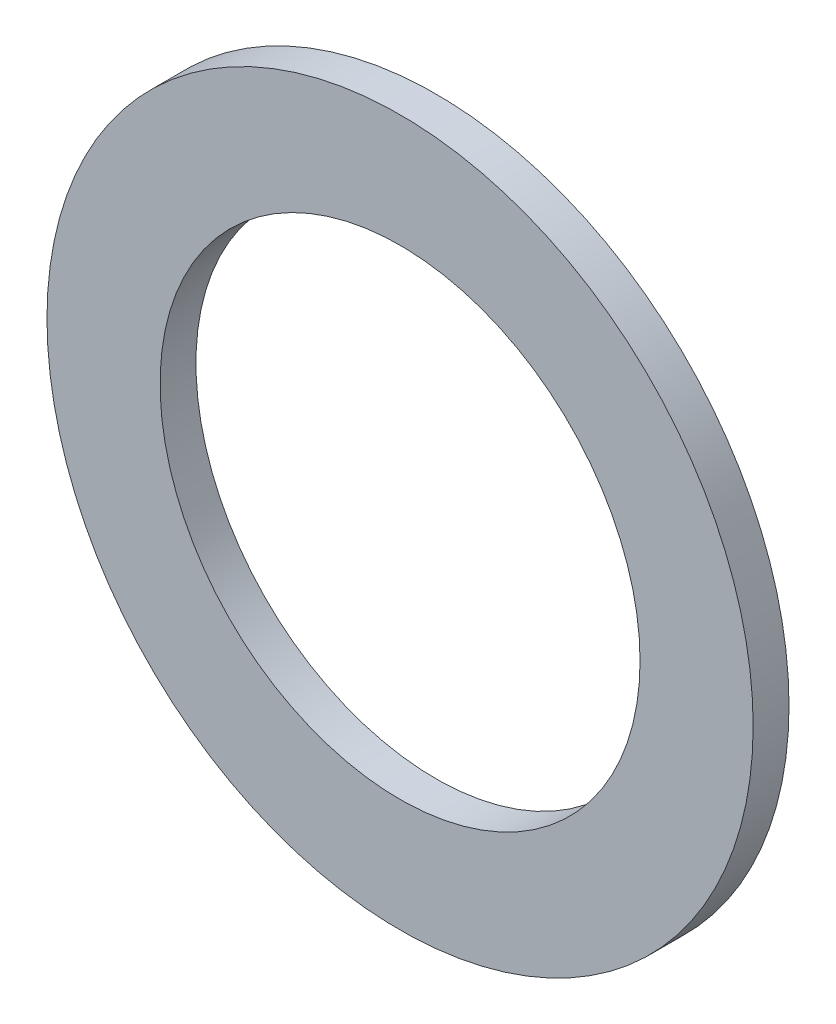
from build123d import *

# Parameters (mm, degrees)
SKETCH1_R           = 128
SKETCH1_R_2         = 87
BOSS_EXTRUDE1_DEPTH = 13


with BuildPart() as part:
    # Sketch1 → Boss-Extrude1 (new body)
    with BuildSketch(Plane.XY):
        Circle(SKETCH1_R)
        Circle(SKETCH1_R_2, mode=Mode.SUBTRACT)
    extrude(amount=BOSS_EXTRUDE1_DEPTH)


solid = part.part
